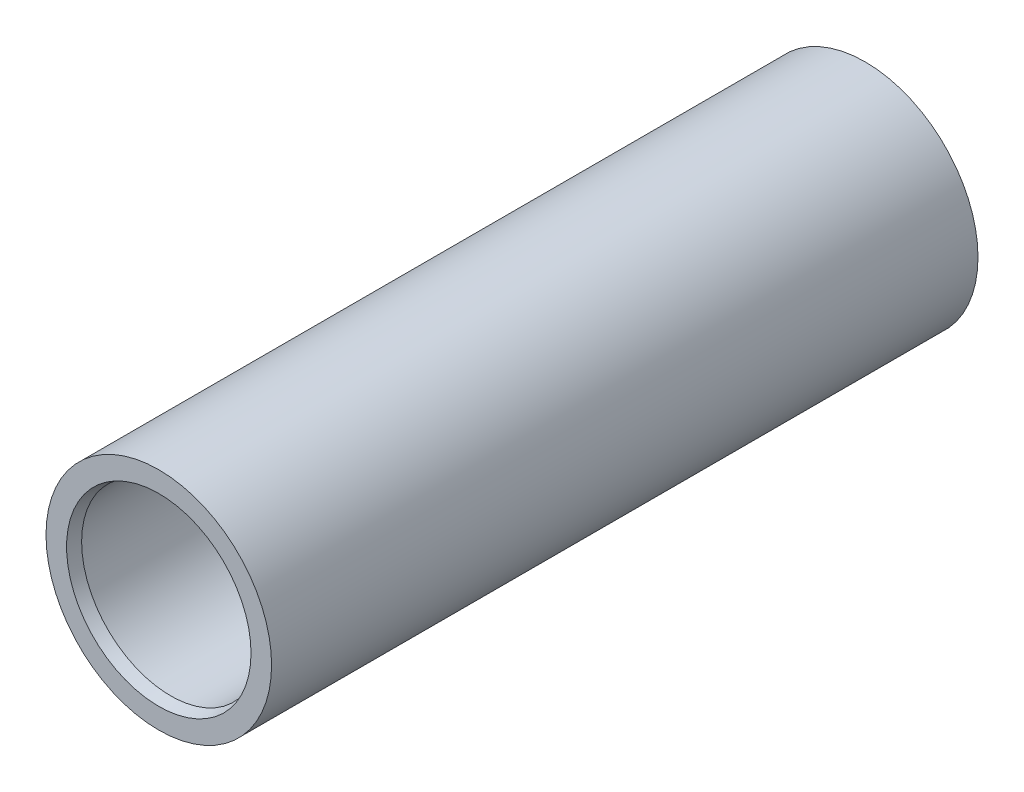
from build123d import *

# Parameters (mm, degrees)
SKETCH1_R           = 38
SKETCH1_R_2         = 30
BOSS_EXTRUDE1_DEPTH = 238
CHAMFER1_SIZE       = 4
CHAMFER1_SIZE2      = 1.07179677
CHAMFER2_SIZE       = 4
CHAMFER2_SIZE2      = 1.07179677


with BuildPart() as part:
    # Sketch1 → Boss-Extrude1 (new body)
    with BuildSketch(Plane.XY):
        Circle(SKETCH1_R)
        Circle(SKETCH1_R_2, mode=Mode.SUBTRACT)
    extrude(amount=BOSS_EXTRUDE1_DEPTH)

    # Chamfer1
    chamfer1_edges = [part.edges().sort_by_distance(p)[0] for p in [
        (-30, 0, 0),
    ]]
    chamfer1_side = [part.faces().sort_by_distance(p)[0] for p in [
        (-30, 0, 119),
    ]]
    chamfer(chamfer1_edges, length=CHAMFER1_SIZE, length2=CHAMFER1_SIZE2, reference=chamfer1_side[0])

    # Chamfer2
    chamfer2_edges = [part.edges().sort_by_distance(p)[0] for p in [
        (-30, 0, 238),
    ]]
    chamfer2_side = [part.faces().sort_by_distance(p)[0] for p in [
        (-30, 0, 121),
    ]]
    chamfer(chamfer2_edges, length=CHAMFER2_SIZE, length2=CHAMFER2_SIZE2, reference=chamfer2_side[0])


solid = part.part
